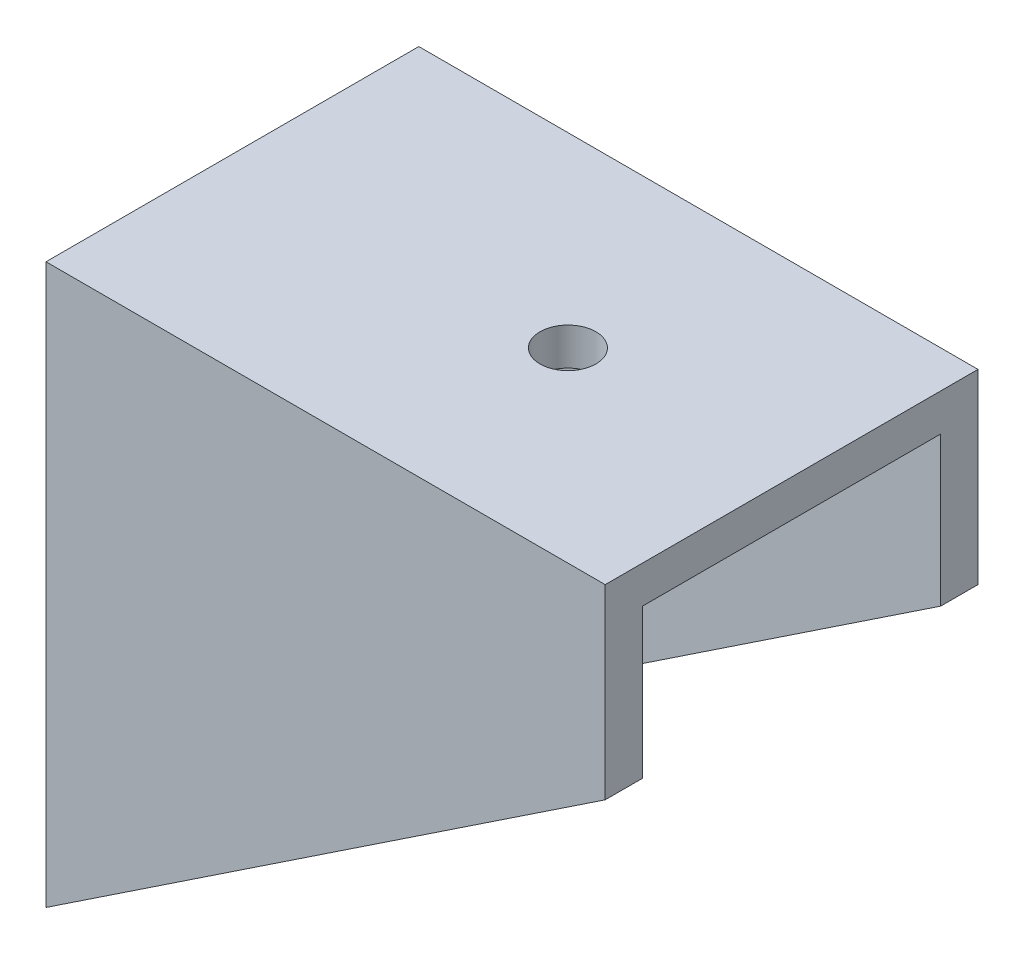
from build123d import *

# Parameters (mm, degrees)
EXTRUDE_1_DEPTH     = 30
CUT_EXTRUDE_1_DEPTH = 21
SKETCH_3_R          = 1.5
CUT_EXTRUDE_2_DEPTH = 31


with BuildPart() as part:
    # Эскиз1 → Вытянуть-Тонкостенный1 (new body)
    with BuildSketch(Plane(origin=(0, 0, 0), x_dir=(0, 0, -1), z_dir=(1, 0, 0))):
        Polygon((0, 0), (0, 30), (20, 30), (20, 0), (18, 0), (18, 28), (2, 28), (2, 0), align=None)
    extrude(amount=EXTRUDE_1_DEPTH)

    # Эскиз2 → Вырез-Вытянуть1 (cut, through all)
    with BuildSketch(Plane.XY):
        Polygon((0, 0), (30, 20), (30, 0), align=None)
    extrude(amount=-CUT_EXTRUDE_1_DEPTH, mode=Mode.SUBTRACT)

    # Эскиз3 → Вырез-Вытянуть2 (cut, through all)
    with BuildSketch(Plane(origin=(0, 30, 0), x_dir=(1, 0, 0), z_dir=(0, 1, 0))):
        with Locations((18, 10)):
            Circle(SKETCH_3_R)
    extrude(amount=-CUT_EXTRUDE_2_DEPTH, mode=Mode.SUBTRACT)


solid = part.part
